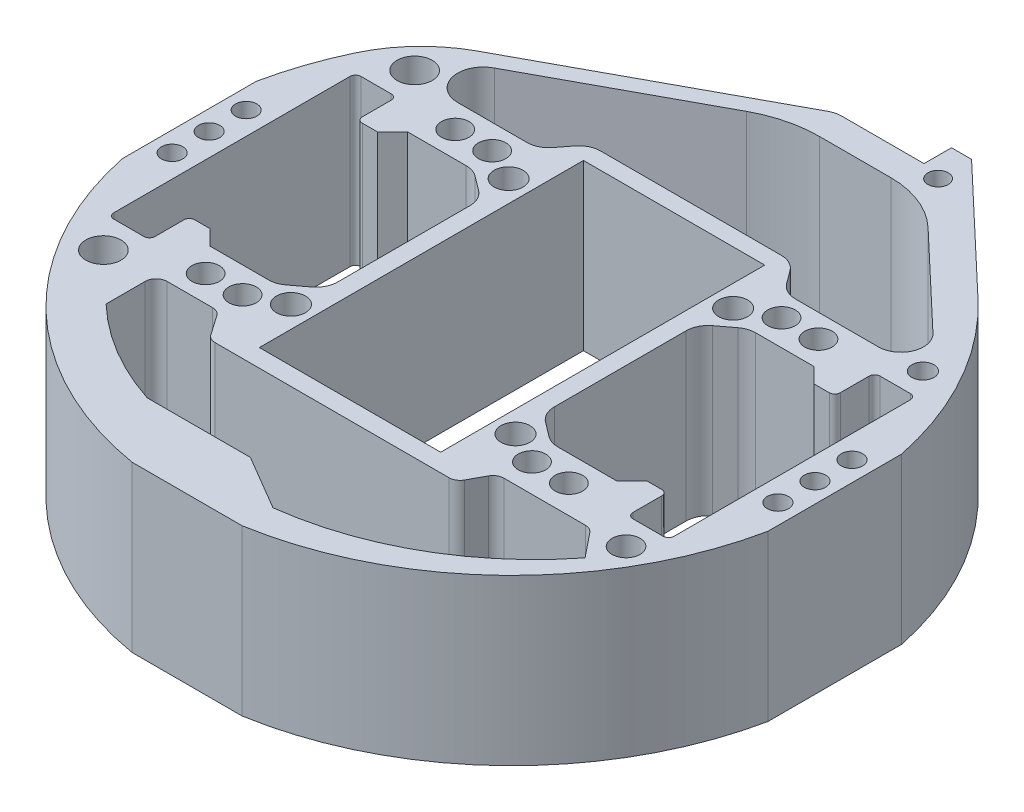
from build123d import *

# Parameters (mm, degrees)
SKETCH1_R           = 2.356484411
SKETCH1_R_2         = 3.356538595
SKETCH1_R_3         = 3.175
SKETCH1_R_4         = 4.064709562
SKETCH1_R_5         = 2.555437721
SKETCH1_R_6         = 3.242334338
SKETCH1_R_7         = 2.462755239
BOSS_EXTRUDE1_DEPTH = 38.1


with BuildPart() as part:
    # Sketch1 → Boss-Extrude1 (new body)
    with BuildSketch(Plane(origin=(0, 0, 0), x_dir=(1, 0, 0), z_dir=(0, 1, 0))):
        with BuildLine():
            Line((-74.6125, 15.473036022), (-74.6125, -15.473036022))
            ThreePointArc((-74.6125, -15.473036022), (-52.874683743, -54.86991725), (-12.7, -75.134213245))
            Line((-12.7, -75.134213245), (12.7, -75.134213245))
            ThreePointArc((12.7, -75.134213245), (52.874683743, -54.86991725), (74.6125, -15.473036022))
            Line((74.6125, -15.473036022), (74.6125, 15.473036022))
            ThreePointArc((74.6125, 15.473036022), (66.568680107, 37.081677804), (52.429845716, 55.295128883))
            Line((52.429845716, 55.295128883), (23.6855, 82.55))
            Line((23.6855, 82.55), (19.05, 82.55))
            Line((19.05, 82.55), (19.05, 76.2))
            Line((19.05, 76.2), (0, 76.2))
            ThreePointArc((0, 76.2), (-1.309576606, 76.036760248), (-2.539006662, 75.557031324))
            Line((-2.539006662, 75.557031324), (-55.150410299, 47.084918442))
            ThreePointArc((-55.150410299, 47.084918442), (-63.168001103, 40.936392006), (-68.874977996, 32.598733198))
            ThreePointArc((-68.874977996, 32.598733198), (-72.252933929, 24.206477205), (-74.6125, 15.473036022))
        make_face()
        with Locations((23.6855, 74.812542953)):
            Circle(SKETCH1_R, mode=Mode.SUBTRACT)
        with Locations((-25.953983408, 25.159074147)):
            Circle(SKETCH1_R_2, mode=Mode.SUBTRACT)
        with Locations((-41.987680119, 28.850105121)):
            Circle(SKETCH1_R_3, mode=Mode.SUBTRACT)
        with Locations((41.987680119, 28.850105121)):
            Circle(SKETCH1_R_3, mode=Mode.SUBTRACT)
        with Locations((-41.987680119, -28.850105121)):
            Circle(SKETCH1_R_3, mode=Mode.SUBTRACT)
        with Locations((41.987680119, -28.850105121)):
            Circle(SKETCH1_R_3, mode=Mode.SUBTRACT)
        with Locations((-33.451838253, 28.850105121)):
            Circle(SKETCH1_R_3, mode=Mode.SUBTRACT)
        with Locations((33.451838253, 28.850105121)):
            Circle(SKETCH1_R_3, mode=Mode.SUBTRACT)
        with Locations((-33.451838253, -28.850105121)):
            Circle(SKETCH1_R_3, mode=Mode.SUBTRACT)
        with Locations((33.451838253, -28.850105121)):
            Circle(SKETCH1_R_3, mode=Mode.SUBTRACT)
        with Locations((-58.499626731, 35.97459363)):
            Circle(SKETCH1_R_4, mode=Mode.SUBTRACT)
        with Locations((60.460006294, 34.52310187)):
            Circle(SKETCH1_R_5, mode=Mode.SUBTRACT)
        with Locations((-58.499626731, -35.97459363)):
            Circle(SKETCH1_R_4, mode=Mode.SUBTRACT)
        with Locations((61.236723994, -34.882223147)):
            Circle(SKETCH1_R_6, mode=Mode.SUBTRACT)
        with Locations((25.953983408, 25.159074147)):
            Circle(SKETCH1_R_2, mode=Mode.SUBTRACT)
        with Locations((25.953983408, -25.159074147)):
            Circle(SKETCH1_R_2, mode=Mode.SUBTRACT)
        with Locations((-25.953983408, -25.159074147)):
            Circle(SKETCH1_R_2, mode=Mode.SUBTRACT)
        with Locations((70.02564652, 8.562540674)):
            Circle(SKETCH1_R_7, mode=Mode.SUBTRACT)
        with Locations((-70.02564652, 8.562540674)):
            Circle(SKETCH1_R_7, mode=Mode.SUBTRACT)
        with Locations((70.02564652, -8.562540674)):
            Circle(SKETCH1_R_7, mode=Mode.SUBTRACT)
        with Locations((-70.02564652, -8.562540674)):
            Circle(SKETCH1_R_7, mode=Mode.SUBTRACT)
        with Locations((-70.02564652, 0)):
            Circle(SKETCH1_R_7, mode=Mode.SUBTRACT)
        with Locations((70.02564652, 0)):
            Circle(SKETCH1_R_7, mode=Mode.SUBTRACT)
        Polygon((20.955, 37.465), (-20.955, 37.465), (-20.955, 0), (-20.955, -37.465), (20.955, -37.465), (20.955, 0), align=None, mode=Mode.SUBTRACT)
        with BuildLine():
            Line((-53.975, 19.3675), (-50.4825, 19.3675))
            Line((-50.4825, 19.3675), (-46.99, 22.86))
            Line((-46.99, 22.86), (-33.451838253, 22.86))
            ThreePointArc((-33.451838253, 22.86), (-31.838145049, 22.596886364), (-30.391611171, 21.834800884))
            Line((-30.391611171, 21.834800884), (-27.038772918, 19.304356919))
            ThreePointArc((-27.038772918, 19.304356919), (-25.551893581, 17.514555641), (-25.019, 15.249556036))
            Line((-25.019, 15.249556036), (-25.019, 0))
            Line((-25.019, 0), (-25.019, -15.249556036))
            ThreePointArc((-25.019, -15.249556036), (-25.551893581, -17.514555641), (-27.038772918, -19.304356919))
            Line((-27.038772918, -19.304356919), (-30.391611171, -21.834800884))
            ThreePointArc((-30.391611171, -21.834800884), (-31.838145049, -22.596886364), (-33.451838253, -22.86))
            Line((-33.451838253, -22.86), (-46.99, -22.86))
            Line((-46.99, -22.86), (-50.4825, -19.3675))
            Line((-50.4825, -19.3675), (-53.975, -19.3675))
            ThreePointArc((-53.975, -19.3675), (-54.873025612, -19.739474388), (-55.245, -20.6375))
            Line((-55.245, -20.6375), (-55.245, -27.305))
            ThreePointArc((-55.245, -27.305), (-55.616974388, -28.203025612), (-56.515, -28.575))
            Line((-56.515, -28.575), (-63.5, -28.575))
            ThreePointArc((-63.5, -28.575), (-64.398025612, -28.203025612), (-64.77, -27.305))
            Line((-64.77, -27.305), (-64.77, 27.305))
            ThreePointArc((-64.77, 27.305), (-64.398025612, 28.203025612), (-63.5, 28.575))
            Line((-63.5, 28.575), (-56.515, 28.575))
            ThreePointArc((-56.515, 28.575), (-55.616974388, 28.203025612), (-55.245, 27.305))
            Line((-55.245, 27.305), (-55.245, 20.6375))
            ThreePointArc((-55.245, 20.6375), (-54.873025612, 19.739474388), (-53.975, 19.3675))
        make_face(mode=Mode.SUBTRACT)
        with BuildLine():
            Line((64.77, 27.305), (64.77, -27.305))
            ThreePointArc((64.77, -27.305), (64.398025612, -28.203025612), (63.5, -28.575))
            Line((63.5, -28.575), (56.515, -28.575))
            ThreePointArc((56.515, -28.575), (55.616974388, -28.203025612), (55.245, -27.305))
            Line((55.245, -27.305), (55.245, -20.6375))
            ThreePointArc((55.245, -20.6375), (54.873025612, -19.739474388), (53.975, -19.3675))
            Line((53.975, -19.3675), (50.4825, -19.3675))
            Line((50.4825, -19.3675), (46.99, -22.86))
            Line((46.99, -22.86), (33.451838253, -22.86))
            ThreePointArc((33.451838253, -22.86), (31.838145049, -22.596886364), (30.391611171, -21.834800884))
            Line((30.391611171, -21.834800884), (27.038772918, -19.304356919))
            ThreePointArc((27.038772918, -19.304356919), (25.551893581, -17.514555641), (25.019, -15.249556036))
            Line((25.019, -15.249556036), (25.019, 0))
            Line((25.019, 0), (25.019, 15.249556036))
            ThreePointArc((25.019, 15.249556036), (25.551893581, 17.514555641), (27.038772918, 19.304356919))
            Line((27.038772918, 19.304356919), (30.391611171, 21.834800884))
            ThreePointArc((30.391611171, 21.834800884), (31.838145049, 22.596886364), (33.451838253, 22.86))
            Line((33.451838253, 22.86), (46.99, 22.86))
            Line((46.99, 22.86), (50.4825, 19.3675))
            Line((50.4825, 19.3675), (53.975, 19.3675))
            ThreePointArc((53.975, 19.3675), (54.873025612, 19.739474388), (55.245, 20.6375))
            Line((55.245, 20.6375), (55.245, 27.305))
            ThreePointArc((55.245, 27.305), (55.616974388, 28.203025612), (56.515, 28.575))
            Line((56.515, 28.575), (63.5, 28.575))
            ThreePointArc((63.5, 28.575), (64.398025612, 28.203025612), (64.77, 27.305))
        make_face(mode=Mode.SUBTRACT)
        with BuildLine():
            Line((-20.845950883, 41.338131188), (0, 41.338131188))
            Line((0, 41.338131188), (20.900876069, 41.338131188))
            ThreePointArc((20.900876069, 41.338131188), (23.189592711, 40.793346302), (24.987420284, 39.275838327))
            Line((24.987420284, 39.275838327), (27.196988383, 36.283666683))
            ThreePointArc((27.196988383, 36.283666683), (28.994815956, 34.766158708), (31.283532598, 34.221373822))
            Line((31.283532598, 34.221373822), (50.45628088, 34.221373822))
            ThreePointArc((50.45628088, 34.221373822), (55.31708187, 37.516208085), (54.056832983, 43.251632379))
            Line((54.056832983, 43.251632379), (32.348707377, 63.834886263))
            ThreePointArc((32.348707377, 63.834886263), (25.730530949, 68.068574663), (18.014985698, 69.550039535))
            Line((18.014985698, 69.550039535), (1.55163213, 69.550039535))
            ThreePointArc((1.55163213, 69.550039535), (-5.413950327, 68.681774216), (-11.953236682, 66.130116403))
            Line((-11.953236682, 66.130116403), (-49.707341043, 45.69844101))
            ThreePointArc((-49.707341043, 45.69844101), (-52.830230484, 39.073656263), (-47.091531492, 34.52310187))
            Line((-47.091531492, 34.52310187), (-31.086999544, 34.52310187))
            ThreePointArc((-31.086999544, 34.52310187), (-28.840846685, 35.046656179), (-27.057679262, 36.509402133))
            Line((-27.057679262, 36.509402133), (-24.875271165, 39.351830925))
            ThreePointArc((-24.875271165, 39.351830925), (-23.092103742, 40.814576878), (-20.845950883, 41.338131188))
        make_face(mode=Mode.SUBTRACT)
        with BuildLine():
            Line((-23.854336738, -60.495536567), (0, -60.495536567))
            Line((0, -60.495536567), (12.7, -67.96894498))
            ThreePointArc((12.7, -67.96894498), (38.322472705, -59.497281046), (58.80689112, -41.928308409))
            Line((58.80689112, -41.928308409), (54.275996481, -36.293661738))
            ThreePointArc((54.275996481, -36.293661738), (53.394000982, -35.594661364), (52.296567671, -35.345346879))
            Line((52.296567671, -35.345346879), (33.457769344, -35.345346879))
            ThreePointArc((33.457769344, -35.345346879), (32.159314658, -35.702317921), (31.225829045, -36.672893786))
            Line((31.225829045, -36.672893786), (29.270713217, -40.271962344))
            ThreePointArc((29.270713217, -40.271962344), (28.337227604, -41.242538208), (27.038772918, -41.599509251))
            Line((27.038772918, -41.599509251), (-27.038772918, -41.599509251))
            ThreePointArc((-27.038772918, -41.599509251), (-28.216614381, -41.30990688), (-29.125868694, -40.507138769))
            Line((-29.125868694, -40.507138769), (-32.269685191, -35.97459363))
            ThreePointArc((-32.269685191, -35.97459363), (-33.178939505, -35.171825519), (-34.356780968, -34.882223147))
            Line((-34.356780968, -34.882223147), (-44.859278162, -34.882223147))
            ThreePointArc((-44.859278162, -34.882223147), (-46.655329386, -35.626171923), (-47.399278162, -37.422223147))
            Line((-47.399278162, -37.422223147), (-47.399278162, -46.454771748))
            ThreePointArc((-47.399278162, -46.454771748), (-36.419314032, -54.804107481), (-23.854336738, -60.495536567))
        make_face(mode=Mode.SUBTRACT)
    extrude(amount=BOSS_EXTRUDE1_DEPTH)


solid = part.part
